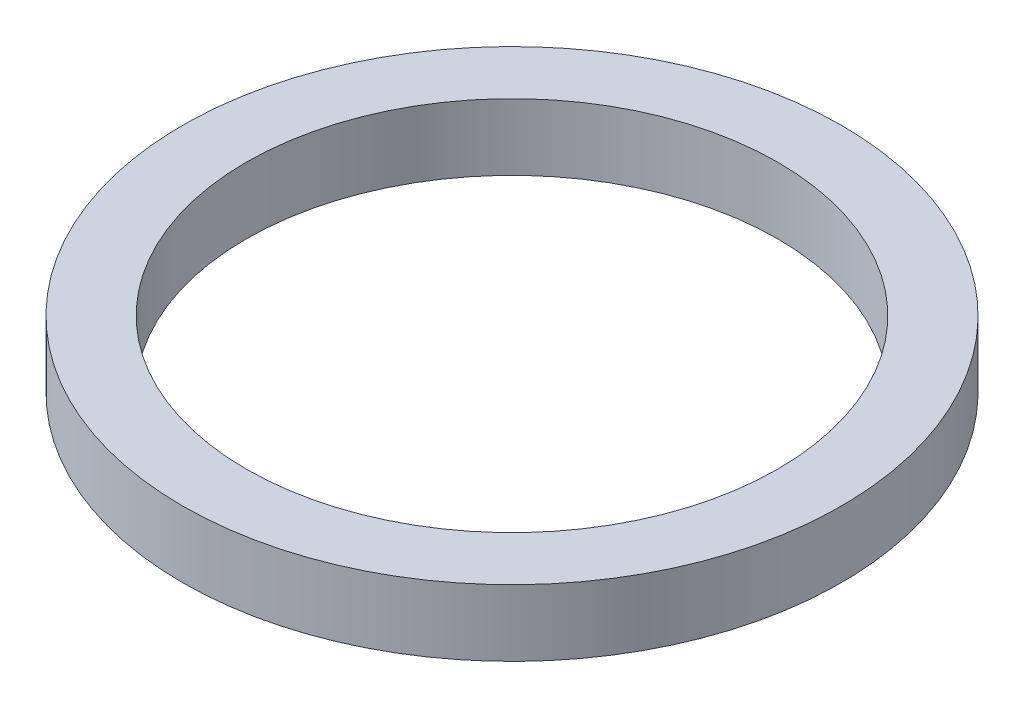
from build123d import *

# Parameters (mm, degrees)
SKETCH1_R           = 7.874
SKETCH1_R_2         = 6.35
BOSS_EXTRUDE1_DEPTH = 1.5875


with BuildPart() as part:
    # Sketch1 → Boss-Extrude1 (new body)
    with BuildSketch(Plane(origin=(0, 0, 0), x_dir=(1, 0, 0), z_dir=(0, 1, 0))):
        Circle(SKETCH1_R)
        Circle(SKETCH1_R_2, mode=Mode.SUBTRACT)
    extrude(amount=BOSS_EXTRUDE1_DEPTH)


solid = part.part
